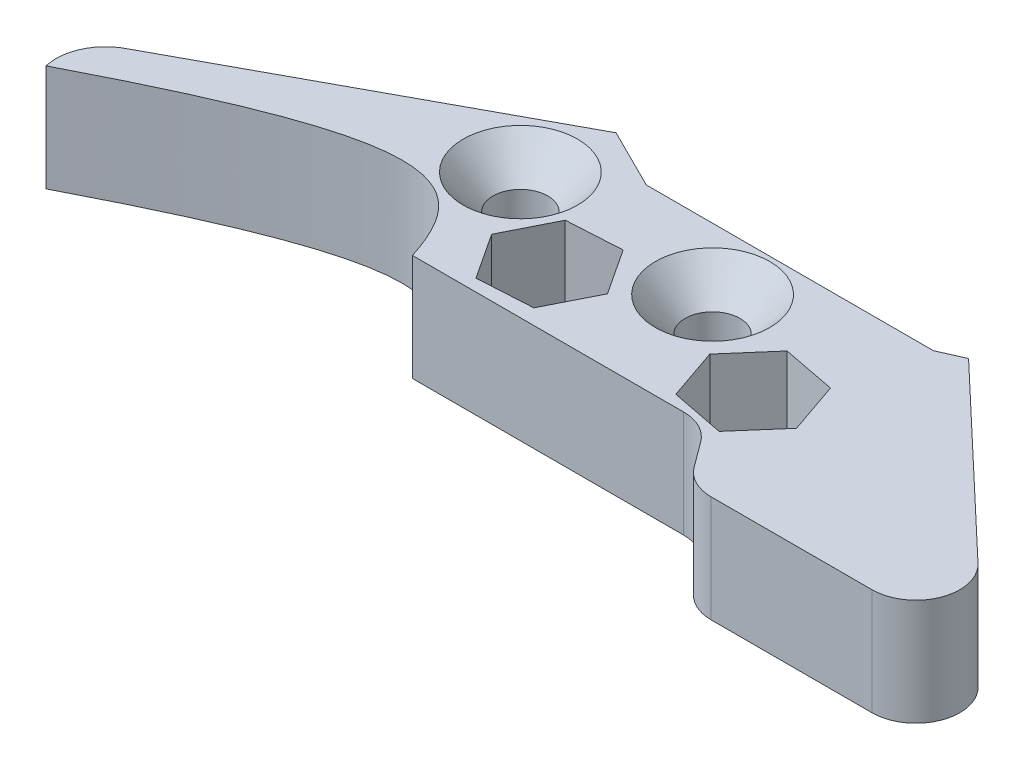
from build123d import *

# Parameters (mm, degrees)
SKETCH1_R             = 3.2639
BOSS_EXTRUDE1_DEPTH   = 12.7
CHAMFER1_SIZE         = 4.0894
CHAMFER1_SIZE2        = 3.554861186
CHAMFER1_PART_2_SIZE  = 4.0894
CHAMFER1_PART_2_SIZE2 = 3.554861186
CUT_EXTRUDE1_DEPTH    = 13.7000001


with BuildPart() as part:
    # Sketch1 → Boss-Extrude1 (new body)
    with BuildSketch(Plane(origin=(0, 0, 0), x_dir=(1, 0, 0), z_dir=(0, 1, 0))):
        with BuildLine():
            Line((98.733031573, -68.985835228), (100.942599672, -71.978006872))
            ThreePointArc((100.942599672, -71.978006872), (102.740427245, -73.495514847), (105.029143887, -74.040299732))
            Line((105.029143887, -74.040299732), (124.201892168, -74.040299732))
            ThreePointArc((124.201892168, -74.040299732), (129.062693158, -70.745465469), (127.802444272, -65.010041176))
            Line((127.802444272, -65.010041176), (106.094318665, -44.426787292))
            Line((106.094318665, -44.426787292), (103.19820861, -45.713487798))
            Line((103.19820861, -45.713487798), (68.977352979, -45.713487798))
            Line((68.977352979, -45.713487798), (61.792374607, -42.131557151))
            Line((61.792374607, -42.131557151), (24.038270246, -62.563232545))
            ThreePointArc((24.038270246, -62.563232545), (21.322907648, -65.331673968), (20.915380805, -69.188017292))
            add(Edge.make_bspline(
                [(62.315611289, -66.923542367), (58.569118303, -55.043460273), (51.499770267, -53.452589153), (20.915380805, -69.188017292)],
                knots=[0, 0, 0, 0, 1, 1, 1, 1], degree=3))
            Line((62.315611289, -66.923542367), (94.646487358, -66.923542367))
            ThreePointArc((94.646487358, -66.923542367), (96.935204, -67.468327252), (98.733031573, -68.985835228))
        make_face()
        with Locations((60.150170667, -51.891201826)):
            Circle(SKETCH1_R, mode=Mode.SUBTRACT)
        with Locations((71.3764156, -59.641849895)):
            Circle(SKETCH1_R, mode=Mode.SUBTRACT)
        with Locations((84.237729699, -53.077081169)):
            Circle(SKETCH1_R, mode=Mode.SUBTRACT)
        with Locations((96.63028976, -60.633621731)):
            Circle(SKETCH1_R, mode=Mode.SUBTRACT)
    extrude(amount=BOSS_EXTRUDE1_DEPTH)

    # Chamfer1
    chamfer1_edges = [part.edges().sort_by_distance(p)[0] for p in [
        (56.886270667, 12.7, 51.891201826),
    ]]
    chamfer1_side = [part.faces().sort_by_distance(p)[0] for p in [
        (56.886270667, 6.35, 51.891201826),
    ]]
    chamfer(chamfer1_edges, length=CHAMFER1_SIZE, length2=CHAMFER1_SIZE2, reference=chamfer1_side[0])

    # Chamfer1 part 2
    chamfer1_part_2_edges = [part.edges().sort_by_distance(p)[0] for p in [
        (80.973829699, 12.7, 53.077081169),
    ]]
    chamfer1_part_2_side = [part.faces().sort_by_distance(p)[0] for p in [
        (80.973829699, 6.35, 53.077081169),
    ]]
    chamfer(chamfer1_part_2_edges, length=CHAMFER1_PART_2_SIZE, length2=CHAMFER1_PART_2_SIZE2, reference=chamfer1_part_2_side[0])

    # Sketch2 → Cut-Extrude1 (cut, through all)
    with BuildSketch(Plane(origin=(0, 12.7, 0), x_dir=(1, 0, 0), z_dir=(0, 1, 0))):
        Polygon((77.89856543, -59.263365519), (74.30971343, -53.804260267), (67.7875636, -54.182744643), (64.85426577, -60.020334272), (68.443117769, -65.479439524), (74.9652676, -65.100955148), align=None)
        Polygon((103.042754495, -61.883415654), (100.918875415, -55.705161331), (94.50641068, -54.455367408), (90.217825025, -59.383827808), (92.341704106, -65.562082131), (98.754168841, -66.811876054), align=None)
    extrude(amount=-CUT_EXTRUDE1_DEPTH, mode=Mode.SUBTRACT)


solid = part.part
